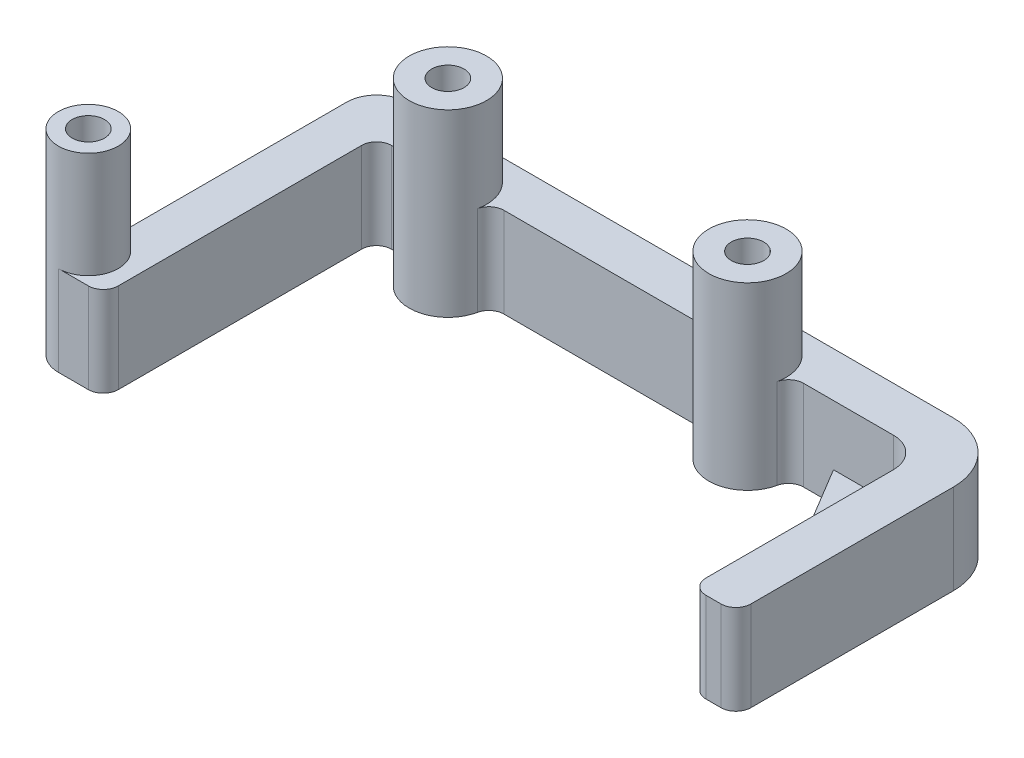
from build123d import *
from build123d.topology import SkipClean

# Parameters (mm, degrees)
SKETCH2_R                      = 3.429
BOSS_EXTRUDE1_DEPTH            = 19.05
SKETCH3_R                      = 8.1915
SKETCH3_R_2                    = 3.429
SKETCH3_R_3                    = 6.35
BOSS_EXTRUDE2_DEPTH            = 19.05
SKETCH4_R                      = 6.35
SKETCH4_R_2                    = 3.429
BOSS_EXTRUDE5_DEPTH            = 3.429
BOSS_EXTRUDE6_START            = -19.05
BOSS_EXTRUDE6_DEPTH            = 6.35
CUT_EXTRUDE2_REACH             = 162.972
SKETCH7_W                      = 141.2875
SKETCH7_H                      = 67.437060646
CUT_EXTRUDE2_DIRECTION_2_REACH = 162.972


with BuildPart() as part:
    # Sketch2 → Boss-Extrude1 (new body)
    with BuildSketch(Plane(origin=(0, 0, 0), x_dir=(1, 0, 0), z_dir=(0, 1, 0))):
        with BuildLine():
            Line((57.144932013, -15.875), (98.430067987, -15.875))
            ThreePointArc((98.430067987, -15.875), (100.422636409, -16.578098691), (101.532702627, -18.375994594))
            ThreePointArc((101.532702627, -18.375994594), (109.5375, -24.828560646), (117.542297372, -18.375994594))
            ThreePointArc((117.542297372, -18.375994594), (118.652363591, -16.578098691), (120.644932013, -15.875))
            Line((120.644932013, -15.875), (122.2375, -15.875))
            ThreePointArc((122.2375, -15.875), (124.48256403, -16.80493597), (125.4125, -19.05))
            Line((125.4125, -19.05), (125.4125, -70.612060646))
            ThreePointArc((125.4125, -70.612060646), (126.34243597, -72.857124676), (128.5875, -73.787060646))
            Line((128.5875, -73.787060646), (134.9375, -73.787060646))
            ThreePointArc((134.9375, -73.787060646), (141.196050854, -68.510858211), (137.054166667, -61.450223232))
            ThreePointArc((137.054166667, -61.450223232), (135.520123355, -60.28989163), (134.9375, -58.456804525))
            Line((134.9375, -58.456804525), (134.9375, -12.7))
            ThreePointArc((134.9375, -12.7), (133.07762806, -8.209871939), (128.5875, -6.35))
            Line((128.5875, -6.35), (12.7, -6.35))
            ThreePointArc((12.7, -6.35), (3.719743879, -10.069743879), (0, -19.05))
            Line((0, -19.05), (0, -61.948583794))
            ThreePointArc((0, -61.948583794), (0.92993597, -64.193647824), (3.175, -65.123583794))
            Line((3.175, -65.123583794), (6.35, -65.123583794))
            ThreePointArc((6.35, -65.123583794), (8.59506403, -64.193647824), (9.525, -61.948583794))
            Line((9.525, -61.948583794), (9.525, -22.225))
            ThreePointArc((9.525, -22.225), (11.384871939, -17.734871939), (15.875, -15.875))
            Line((15.875, -15.875), (34.930067987, -15.875))
            ThreePointArc((34.930067987, -15.875), (36.922636409, -16.578098691), (38.032702627, -18.375994594))
            ThreePointArc((38.032702627, -18.375994594), (46.0375, -24.828560646), (54.042297372, -18.375994594))
            ThreePointArc((54.042297372, -18.375994594), (55.152363591, -16.578098691), (57.144932013, -15.875))
        make_face()
        with Locations(Location((46.0375, -16.637060646, 0), (0, 0, 270))):
            Circle(SKETCH2_R, mode=Mode.SUBTRACT)
        with Locations(Location((109.5375, -16.637060646, 0), (0, 0, 270))):
            Circle(SKETCH2_R, mode=Mode.SUBTRACT)
        with Locations(Location((134.9375, -67.437060646, 0), (0, 0, 270))):
            Circle(SKETCH2_R, mode=Mode.SUBTRACT)
    boss_extrude1 = extrude(amount=-BOSS_EXTRUDE1_DEPTH)

    # Sketch3 → Boss-Extrude2 (add)
    with BuildSketch(Plane(origin=(0, 0, 0), x_dir=(1, 0, 0), z_dir=(0, 1, 0))):
        with Locations(Location((46.0375, -16.637060646, 0), (0, 0, 270))):
            Circle(SKETCH3_R)
        with Locations(Location((46.0375, -16.637060646, 0), (0, 0, 270))):
            Circle(SKETCH3_R_2, mode=Mode.SUBTRACT)
        with Locations(Location((109.5375, -16.637060646, 0), (0, 0, 270))):
            Circle(SKETCH3_R)
        with Locations(Location((109.5375, -16.637060646, 0), (0, 0, 270))):
            Circle(SKETCH3_R_2, mode=Mode.SUBTRACT)
        with Locations(Location((134.9375, -67.437060646, 0), (0, 0, 270))):
            Circle(SKETCH3_R_3)
        with Locations(Location((134.9375, -67.437060646, 0), (0, 0, 270))):
            Circle(SKETCH3_R_2, mode=Mode.SUBTRACT)
    boss_extrude2 = extrude(amount=BOSS_EXTRUDE2_DEPTH)

    # Sketch4 → Boss-Extrude5 (add)
    with BuildSketch(Plane(origin=(0, 19.05, 0), x_dir=(1, 0, 0), z_dir=(0, 1, 0))):
        with Locations(Location((134.9375, -67.437060646, 0), (0, 0, 270))):
            Circle(SKETCH4_R)
        with Locations(Location((134.9375, -67.437060646, 0), (0, 0, 270))):
            Circle(SKETCH4_R_2, mode=Mode.SUBTRACT)
    boss_extrude5 = extrude(amount=BOSS_EXTRUDE5_DEPTH)

    # Sketch6 → Boss-Extrude6 (add)
    with BuildSketch(Plane(origin=(0, 0, 0), x_dir=(1, 0, 0), z_dir=(0, 1, 0)).offset(BOSS_EXTRUDE6_START)):
        Polygon((28.575, -15.875), (9.525, -47.625), (9.525, -15.875), align=None)
    boss_extrude6 = extrude(amount=BOSS_EXTRUDE6_DEPTH)

    # Mirror4: Boss-Extrude1, Boss-Extrude2, Boss-Extrude5, Boss-Extrude6 across plane
    with SkipClean():  # the faces are left unmerged after this step: merging them gives an invalid solid
        add(boss_extrude1.mirror(Plane(origin=(0, -19.05, 19.05), x_dir=(0, 0, 1), z_dir=(-1, 0, 0))))
        add(boss_extrude2.mirror(Plane(origin=(0, -19.05, 19.05), x_dir=(0, 0, 1), z_dir=(-1, 0, 0))))
        add(boss_extrude5.mirror(Plane(origin=(0, -19.05, 19.05), x_dir=(0, 0, 1), z_dir=(-1, 0, 0))))
        add(boss_extrude6.mirror(Plane(origin=(0, -19.05, 19.05), x_dir=(0, 0, 1), z_dir=(-1, 0, 0))))

    # Cut-Extrude2: up to this face of the body (flat: up to its plane)
    cut_extrude2_end = Plane(part.part.faces().sort_by_distance((134.9375, 22.479, 61.266665768))[0])
    # Sketch7 → Cut-Extrude2 (cut, up to the picked face)
    with BuildSketch(Plane(origin=(0, 0, 0), x_dir=(1, 0, 0), z_dir=(0, 1, 0)), mode=Mode.PRIVATE) as cut_extrude2_sk1:
        with Locations((70.64375, -40.068530323)):
            Rectangle(SKETCH7_W, SKETCH7_H)
    cut_extrude2_tool1 = split(extrude(cut_extrude2_sk1.sketch, amount=CUT_EXTRUDE2_REACH, mode=Mode.PRIVATE), bisect_by=cut_extrude2_end, keep=Keep.BOTH, mode=Mode.PRIVATE)
    add(cut_extrude2_tool1.solids().sort_by(Axis((70.64375, 0, 40.06853), (0, 1, 0)))[0], mode=Mode.SUBTRACT)

    # Cut-Extrude2 direction 2: up to this face of the body (flat: up to its plane)
    cut_extrude2_direction_2_end = Plane(part.part.faces().sort_by_distance((0.921292425, -19.05, 25.561080077))[0])
    # Sketch7 → Cut-Extrude2 direction 2 (cut, up to the picked face)
    with BuildSketch(Plane(origin=(0, 0, 0), x_dir=(1, 0, 0), z_dir=(0, 1, 0)), mode=Mode.PRIVATE) as cut_extrude2_direction_2_sk1:
        with Locations((70.64375, -40.068530323)):
            Rectangle(SKETCH7_W, SKETCH7_H)
    cut_extrude2_direction_2_tool1 = split(extrude(cut_extrude2_direction_2_sk1.sketch, amount=-CUT_EXTRUDE2_DIRECTION_2_REACH, mode=Mode.PRIVATE), bisect_by=cut_extrude2_direction_2_end, keep=Keep.BOTH, mode=Mode.PRIVATE)
    add(cut_extrude2_direction_2_tool1.solids().sort_by(Axis((70.64375, 0, 40.06853), (0, -1, 0)))[0], mode=Mode.SUBTRACT)


solid = part.part
